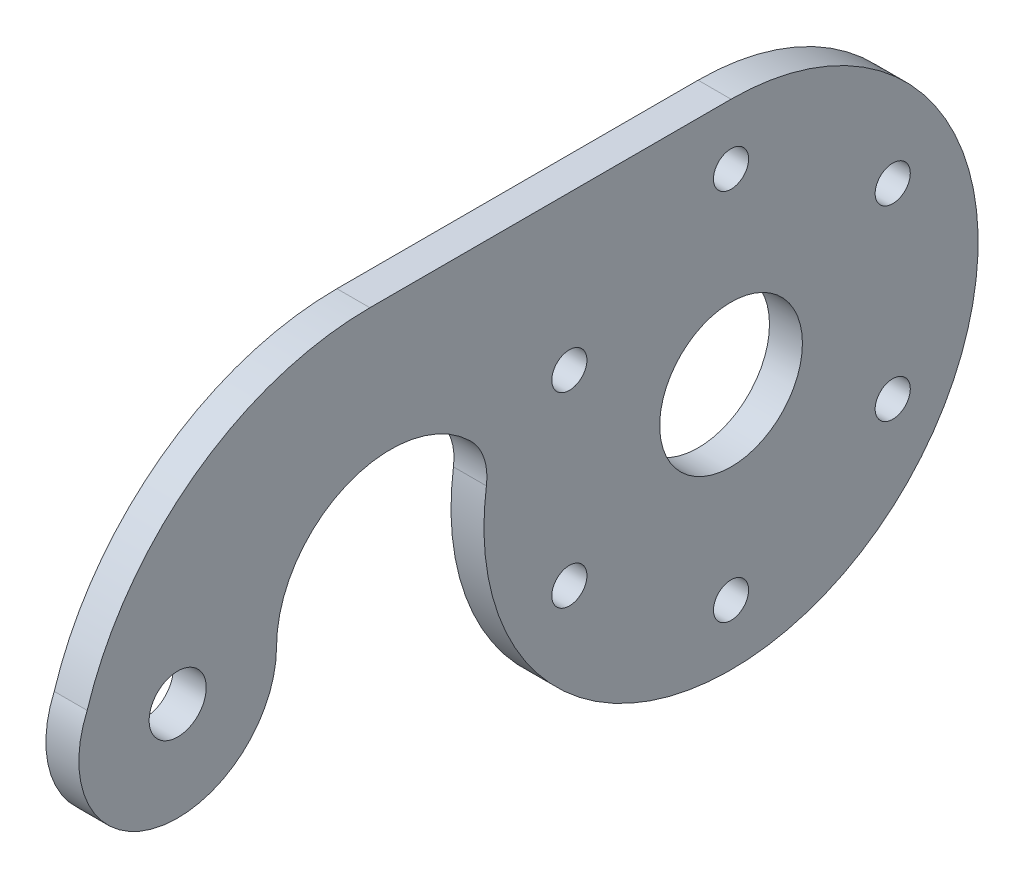
from build123d import *

# Parameters (mm, degrees)
BOSS_EXTRUDE1_DEPTH = 3
FILLET2_R           = 5
SKETCH2_R           = 6.5
SKETCH2_R_2         = 2.6
SKETCH2_R_3         = 1.6
CUT_EXTRUDE1_DEPTH  = 4.0000001


with BuildPart() as part:
    # Sketch1 → Boss-Extrude1 (new body)
    with BuildSketch(Plane(origin=(0, 0, 0), x_dir=(0, 0, -1), z_dir=(1, 0, 0))):
        with BuildLine():
            ThreePointArc((-41.386624325, 0), (-33.610207892, 10.053296954), (-21.925290889, 5.052882289))
            ThreePointArc((-21.925290889, 5.052882289), (14.009999081, -17.60596279), (0, 22.5))
            Line((0, 22.5), (-32.886624325, 22.5))
            ThreePointArc((-32.886624325, 22.5), (-48.850275915, 17.272163951), (-58.62909831, 3.614086692))
            ThreePointArc((-58.62909831, 3.614086692), (-52.232936073, -8.808582913), (-41.386624325, 0))
        make_face()
    extrude(amount=BOSS_EXTRUDE1_DEPTH)

    # Fillet2
    fillet2_edges = [part.edges().sort_by_distance(p)[0] for p in [
        (1.5, 5.052882289, 21.925290889),
    ]]
    fillet(fillet2_edges, radius=FILLET2_R)

    # Sketch2 → Cut-Extrude1 (cut, through all)
    with BuildSketch(Plane(origin=(3, 0, 0), x_dir=(0, 0, -1), z_dir=(1, 0, 0))):
        Circle(SKETCH2_R)
        with Locations((-50.386624325, 0)):
            Circle(SKETCH2_R_2)
        with Locations((0, 17)):
            Circle(SKETCH2_R_3)
        with Locations((14.722431864, 8.5)):
            Circle(SKETCH2_R_3)
        with Locations((14.722431864, -8.5)):
            Circle(SKETCH2_R_3)
        with Locations((0, -17)):
            Circle(SKETCH2_R_3)
        with Locations((-14.722431864, -8.5)):
            Circle(SKETCH2_R_3)
        with Locations((-14.722431864, 8.5)):
            Circle(SKETCH2_R_3)
    extrude(amount=-CUT_EXTRUDE1_DEPTH, mode=Mode.SUBTRACT)


solid = part.part
